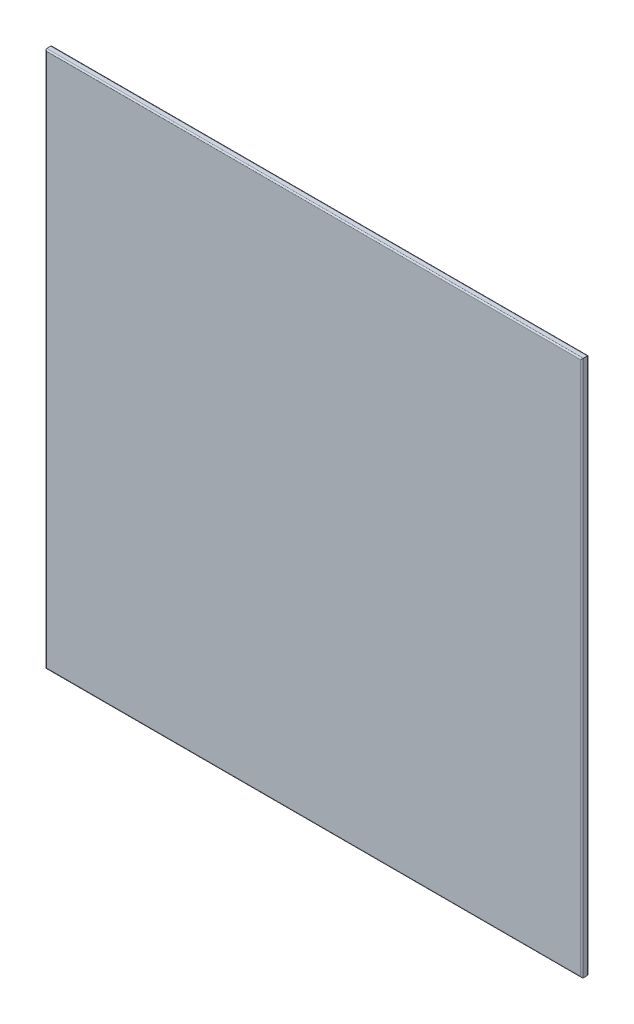
from build123d import *

# Parameters (mm, degrees)
SKETCH1_W           = 1220
SKETCH1_H           = 1220
BOSS_EXTRUDE1_DEPTH = 15
FILLET1_R           = 3


with BuildPart() as part:
    # Sketch1 → Boss-Extrude1 (new body)
    with BuildSketch(Plane.XY):
        Rectangle(SKETCH1_W, SKETCH1_H)
    extrude(amount=BOSS_EXTRUDE1_DEPTH)

    # Fillet1
    fillet1_edges = [part.edges().sort_by_distance(p)[0] for p in [
        (610, 0, 15),
        (0, 610, 15),
        (-610, 0, 15),
        (0, 610, 0),
        (610, 0, 0),
        (0, -610, 0),
        (-610, 0, 0),
        (0, -610, 15),
    ]]
    fillet(fillet1_edges, radius=FILLET1_R)


solid = part.part
